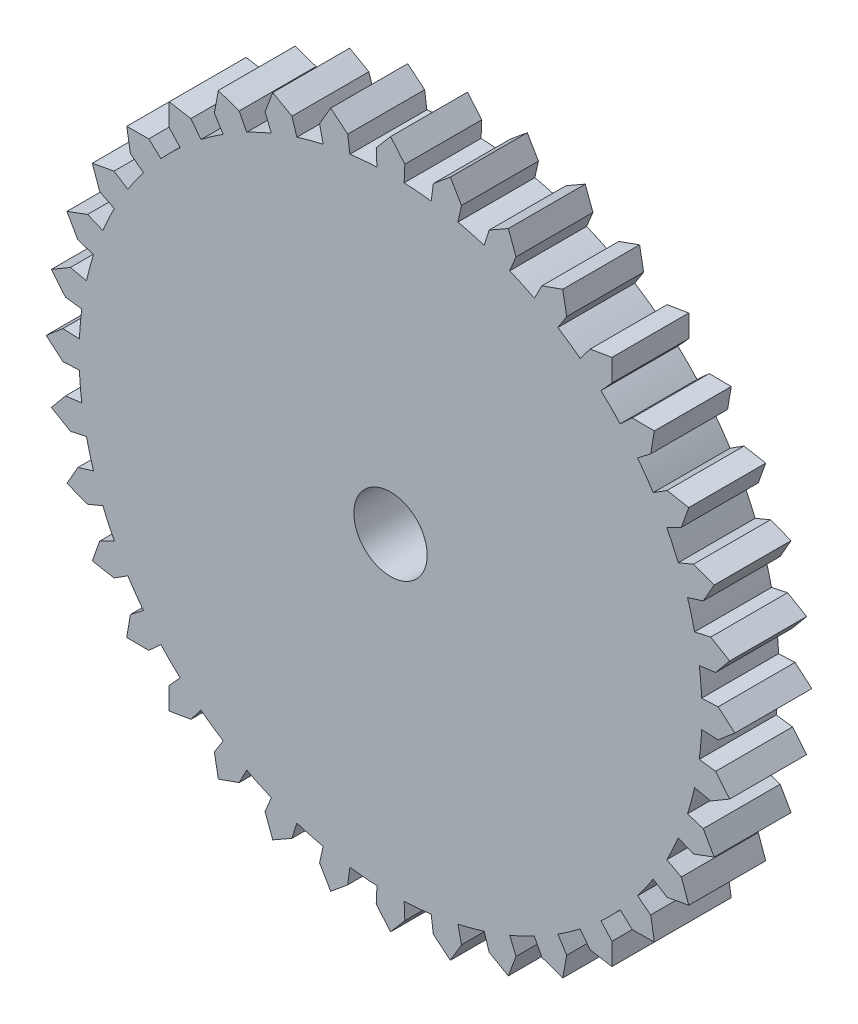
from build123d import *

# Parameters (mm, degrees)
SKETCH1_R           = 1
BOSS_EXTRUDE1_DEPTH = 2.1
SKETCH2_R           = 1
BOSS_EXTRUDE2_DEPTH = 3.5


with BuildPart() as part:
    # Sketch1 → Boss-Extrude1 (new body)
    with BuildSketch(Plane.XY):
        with BuildLine():
            Line((1.63229287, 9.257192878), (1.937134545, 8.737849264))
            Line((1.937134545, 8.737849264), (1.839736718, 8.298516061))
            ThreePointArc((1.839736718, 8.298516061), (2.020330085, 8.256407593), (2.199961883, 8.210369523))
            ThreePointArc((2.199961883, 8.210369523), (2.378546619, 8.160423762), (2.555999296, 8.106594081))
            Line((2.555999296, 8.106594081), (2.691316906, 8.535766709))
            Line((2.691316906, 8.535766709), (3.214989347, 8.833110635))
            Line((3.214989347, 8.833110635), (3.42501672, 8.268721816))
            Line((3.42501672, 8.268721816), (3.252809175, 7.852976026))
            ThreePointArc((3.252809175, 7.852976026), (3.423346864, 7.780147573), (3.592255225, 7.70361619))
            ThreePointArc((3.592255225, 7.70361619), (3.759453867, 7.623418303), (3.924863212, 7.539592082))
            Line((3.924863212, 7.539592082), (4.132650088, 7.938746957))
            Line((4.132650088, 7.938746957), (4.7, 8.140638796))
            Line((4.7, 8.140638796), (4.808831495, 7.54835344))
            Line((4.808831495, 7.54835344), (4.567046671, 7.168827289))
            ThreePointArc((4.567046671, 7.168827289), (4.722346981, 7.067491705), (4.875399709, 6.962792376))
            ThreePointArc((4.875399709, 6.962792376), (5.026132011, 6.854779136), (5.174472147, 6.743503392))
            Line((5.174472147, 6.743503392), (5.44841479, 7.100512396))
            Line((5.44841479, 7.100512396), (6.042203531, 7.200817765))
            Line((6.042203531, 7.200817765), (6.046532358, 6.598632164))
            Line((6.046532358, 6.598632164), (5.742516765, 6.266857363))
            ThreePointArc((5.742516765, 6.266857363), (5.877860974, 6.140093678), (6.01040764, 6.01040764))
            ThreePointArc((6.01040764, 6.01040764), (6.140093678, 5.877860974), (6.266857363, 5.742516765))
            Line((6.266857363, 5.742516765), (6.598632164, 6.046532358))
            Line((6.598632164, 6.046532358), (7.200817765, 6.042203531))
            Line((7.200817765, 6.042203531), (7.100512396, 5.44841479))
            Line((7.100512396, 5.44841479), (6.743503392, 5.174472147))
            ThreePointArc((6.743503392, 5.174472147), (6.854779136, 5.026132011), (6.962792376, 4.875399709))
            ThreePointArc((6.962792376, 4.875399709), (7.067491705, 4.722346981), (7.168827289, 4.567046671))
            Line((7.168827289, 4.567046671), (7.54835344, 4.808831495))
            Line((7.54835344, 4.808831495), (8.140638796, 4.7))
            Line((8.140638796, 4.7), (7.938746957, 4.132650088))
            Line((7.938746957, 4.132650088), (7.539592082, 3.924863212))
            ThreePointArc((7.539592082, 3.924863212), (7.623418303, 3.759453867), (7.70361619, 3.592255225))
            ThreePointArc((7.70361619, 3.592255225), (7.780147573, 3.423346864), (7.852976026, 3.252809175))
            Line((7.852976026, 3.252809175), (8.268721816, 3.42501672))
            Line((8.268721816, 3.42501672), (8.833110635, 3.214989347))
            Line((8.833110635, 3.214989347), (8.535766709, 2.691316906))
            Line((8.535766709, 2.691316906), (8.106594081, 2.555999296))
            ThreePointArc((8.106594081, 2.555999296), (8.160423762, 2.378546619), (8.210369523, 2.199961883))
            ThreePointArc((8.210369523, 2.199961883), (8.256407593, 2.020330085), (8.298516061, 1.839736718))
            Line((8.298516061, 1.839736718), (8.737849264, 1.937134545))
            Line((8.737849264, 1.937134545), (9.257192878, 1.63229287))
            Line((9.257192878, 1.63229287), (8.873431509, 1.16820942))
            Line((8.873431509, 1.16820942), (8.427281322, 1.109472634))
            ThreePointArc((8.427281322, 1.109472634), (8.449478875, 0.925368436), (8.467654934, 0.740823813))
            ThreePointArc((8.467654934, 0.740823813), (8.481800848, 0.555926598), (8.491909883, 0.370764793))
            Line((8.491909883, 0.370764793), (8.941481583, 0.390393517))
            Line((8.941481583, 0.390393517), (9.4, 0))
            Line((9.4, 0), (8.941481583, -0.390393517))
            Line((8.941481583, -0.390393517), (8.491909883, -0.370764793))
            ThreePointArc((8.491909883, -0.370764793), (8.481800848, -0.555926598), (8.467654934, -0.740823813))
            ThreePointArc((8.467654934, -0.740823813), (8.449478875, -0.925368436), (8.427281322, -1.109472634))
            Line((8.427281322, -1.109472634), (8.873431509, -1.16820942))
            Line((8.873431509, -1.16820942), (9.257192878, -1.63229287))
            Line((9.257192878, -1.63229287), (8.737849264, -1.937134545))
            Line((8.737849264, -1.937134545), (8.298516061, -1.839736718))
            ThreePointArc((8.298516061, -1.839736718), (8.256407593, -2.020330085), (8.210369523, -2.199961883))
            ThreePointArc((8.210369523, -2.199961883), (8.160423762, -2.378546619), (8.106594081, -2.555999296))
            Line((8.106594081, -2.555999296), (8.535766709, -2.691316906))
            Line((8.535766709, -2.691316906), (8.833110635, -3.214989347))
            Line((8.833110635, -3.214989347), (8.268721816, -3.42501672))
            Line((8.268721816, -3.42501672), (7.852976026, -3.252809175))
            ThreePointArc((7.852976026, -3.252809175), (7.780147573, -3.423346864), (7.70361619, -3.592255225))
            ThreePointArc((7.70361619, -3.592255225), (7.623418303, -3.759453867), (7.539592082, -3.924863212))
            Line((7.539592082, -3.924863212), (7.938746957, -4.132650088))
            Line((7.938746957, -4.132650088), (8.140638796, -4.7))
            Line((8.140638796, -4.7), (7.54835344, -4.808831495))
            Line((7.54835344, -4.808831495), (7.168827289, -4.567046671))
            ThreePointArc((7.168827289, -4.567046671), (7.067491705, -4.722346981), (6.962792376, -4.875399709))
            ThreePointArc((6.962792376, -4.875399709), (6.854779136, -5.026132011), (6.743503392, -5.174472147))
            Line((6.743503392, -5.174472147), (7.100512396, -5.44841479))
            Line((7.100512396, -5.44841479), (7.200817765, -6.042203531))
            Line((7.200817765, -6.042203531), (6.598632164, -6.046532358))
            Line((6.598632164, -6.046532358), (6.266857363, -5.742516765))
            ThreePointArc((6.266857363, -5.742516765), (6.140093678, -5.877860974), (6.01040764, -6.01040764))
            ThreePointArc((6.01040764, -6.01040764), (5.877860974, -6.140093678), (5.742516765, -6.266857363))
            Line((5.742516765, -6.266857363), (6.046532358, -6.598632164))
            Line((6.046532358, -6.598632164), (6.042203531, -7.200817765))
            Line((6.042203531, -7.200817765), (5.44841479, -7.100512396))
            Line((5.44841479, -7.100512396), (5.174472147, -6.743503392))
            ThreePointArc((5.174472147, -6.743503392), (5.026132011, -6.854779136), (4.875399709, -6.962792376))
            ThreePointArc((4.875399709, -6.962792376), (4.722346981, -7.067491705), (4.567046671, -7.168827289))
            Line((4.567046671, -7.168827289), (4.808831495, -7.54835344))
            Line((4.808831495, -7.54835344), (4.7, -8.140638796))
            Line((4.7, -8.140638796), (4.132650088, -7.938746957))
            Line((4.132650088, -7.938746957), (3.924863212, -7.539592082))
            ThreePointArc((3.924863212, -7.539592082), (3.759453867, -7.623418303), (3.592255225, -7.70361619))
            ThreePointArc((3.592255225, -7.70361619), (3.423346864, -7.780147573), (3.252809175, -7.852976026))
            Line((3.252809175, -7.852976026), (3.42501672, -8.268721816))
            Line((3.42501672, -8.268721816), (3.214989347, -8.833110635))
            Line((3.214989347, -8.833110635), (2.691316906, -8.535766709))
            Line((2.691316906, -8.535766709), (2.555999296, -8.106594081))
            ThreePointArc((2.555999296, -8.106594081), (2.378546619, -8.160423762), (2.199961883, -8.210369523))
            ThreePointArc((2.199961883, -8.210369523), (2.020330085, -8.256407593), (1.839736718, -8.298516061))
            Line((1.839736718, -8.298516061), (1.937134545, -8.737849264))
            Line((1.937134545, -8.737849264), (1.63229287, -9.257192878))
            Line((1.63229287, -9.257192878), (1.16820942, -8.873431509))
            Line((1.16820942, -8.873431509), (1.109472634, -8.427281322))
            ThreePointArc((1.109472634, -8.427281322), (0.925368436, -8.449478875), (0.740823813, -8.467654934))
            ThreePointArc((0.740823813, -8.467654934), (0.555926598, -8.481800848), (0.370764793, -8.491909883))
            Line((0.370764793, -8.491909883), (0.390393517, -8.941481583))
            Line((0.390393517, -8.941481583), (0, -9.4))
            Line((0, -9.4), (-0.390393517, -8.941481583))
            Line((-0.390393517, -8.941481583), (-0.370764793, -8.491909883))
            ThreePointArc((-0.370764793, -8.491909883), (-0.555926598, -8.481800848), (-0.740823813, -8.467654934))
            ThreePointArc((-0.740823813, -8.467654934), (-0.925368436, -8.449478875), (-1.109472634, -8.427281322))
            Line((-1.109472634, -8.427281322), (-1.16820942, -8.873431509))
            Line((-1.16820942, -8.873431509), (-1.63229287, -9.257192878))
            Line((-1.63229287, -9.257192878), (-1.937134545, -8.737849264))
            Line((-1.937134545, -8.737849264), (-1.839736718, -8.298516061))
            ThreePointArc((-1.839736718, -8.298516061), (-2.020330085, -8.256407593), (-2.199961883, -8.210369523))
            ThreePointArc((-2.199961883, -8.210369523), (-2.378546619, -8.160423762), (-2.555999296, -8.106594081))
            Line((-2.555999296, -8.106594081), (-2.691316906, -8.535766709))
            Line((-2.691316906, -8.535766709), (-3.214989347, -8.833110635))
            Line((-3.214989347, -8.833110635), (-3.42501672, -8.268721816))
            Line((-3.42501672, -8.268721816), (-3.252809175, -7.852976026))
            ThreePointArc((-3.252809175, -7.852976026), (-3.423346864, -7.780147573), (-3.592255225, -7.70361619))
            ThreePointArc((-3.592255225, -7.70361619), (-3.759453867, -7.623418303), (-3.924863212, -7.539592082))
            Line((-3.924863212, -7.539592082), (-4.132650088, -7.938746957))
            Line((-4.132650088, -7.938746957), (-4.7, -8.140638796))
            Line((-4.7, -8.140638796), (-4.808831495, -7.54835344))
            Line((-4.808831495, -7.54835344), (-4.567046671, -7.168827289))
            ThreePointArc((-4.567046671, -7.168827289), (-4.722346981, -7.067491705), (-4.875399709, -6.962792376))
            ThreePointArc((-4.875399709, -6.962792376), (-5.026132011, -6.854779136), (-5.174472147, -6.743503392))
            Line((-5.174472147, -6.743503392), (-5.44841479, -7.100512396))
            Line((-5.44841479, -7.100512396), (-6.042203531, -7.200817765))
            Line((-6.042203531, -7.200817765), (-6.046532358, -6.598632164))
            Line((-6.046532358, -6.598632164), (-5.742516765, -6.266857363))
            ThreePointArc((-5.742516765, -6.266857363), (-5.877860974, -6.140093678), (-6.01040764, -6.01040764))
            ThreePointArc((-6.01040764, -6.01040764), (-6.140093678, -5.877860974), (-6.266857363, -5.742516765))
            Line((-6.266857363, -5.742516765), (-6.598632164, -6.046532358))
            Line((-6.598632164, -6.046532358), (-7.200817765, -6.042203531))
            Line((-7.200817765, -6.042203531), (-7.100512396, -5.44841479))
            Line((-7.100512396, -5.44841479), (-6.743503392, -5.174472147))
            ThreePointArc((-6.743503392, -5.174472147), (-6.854779136, -5.026132011), (-6.962792376, -4.875399709))
            ThreePointArc((-6.962792376, -4.875399709), (-7.067491705, -4.722346981), (-7.168827289, -4.567046671))
            Line((-7.168827289, -4.567046671), (-7.54835344, -4.808831495))
            Line((-7.54835344, -4.808831495), (-8.140638796, -4.7))
            Line((-8.140638796, -4.7), (-7.938746957, -4.132650088))
            Line((-7.938746957, -4.132650088), (-7.539592082, -3.924863212))
            ThreePointArc((-7.539592082, -3.924863212), (-7.623418303, -3.759453867), (-7.70361619, -3.592255225))
            ThreePointArc((-7.70361619, -3.592255225), (-7.780147573, -3.423346864), (-7.852976026, -3.252809175))
            Line((-7.852976026, -3.252809175), (-8.268721816, -3.42501672))
            Line((-8.268721816, -3.42501672), (-8.833110635, -3.214989347))
            Line((-8.833110635, -3.214989347), (-8.535766709, -2.691316906))
            Line((-8.535766709, -2.691316906), (-8.106594081, -2.555999296))
            ThreePointArc((-8.106594081, -2.555999296), (-8.160423762, -2.378546619), (-8.210369523, -2.199961883))
            ThreePointArc((-8.210369523, -2.199961883), (-8.256407593, -2.020330085), (-8.298516061, -1.839736718))
            Line((-8.298516061, -1.839736718), (-8.737849264, -1.937134545))
            Line((-8.737849264, -1.937134545), (-9.257192878, -1.63229287))
            Line((-9.257192878, -1.63229287), (-8.873431509, -1.16820942))
            Line((-8.873431509, -1.16820942), (-8.427281322, -1.109472634))
            ThreePointArc((-8.427281322, -1.109472634), (-8.449478875, -0.925368436), (-8.467654934, -0.740823813))
            ThreePointArc((-8.467654934, -0.740823813), (-8.481800848, -0.555926598), (-8.491909883, -0.370764793))
            Line((-8.491909883, -0.370764793), (-8.941481583, -0.390393517))
            Line((-8.941481583, -0.390393517), (-9.4, 0))
            Line((-9.4, 0), (-8.941481583, 0.390393517))
            Line((-8.941481583, 0.390393517), (-8.491909883, 0.370764793))
            ThreePointArc((-8.491909883, 0.370764793), (-8.481800848, 0.555926598), (-8.467654934, 0.740823813))
            ThreePointArc((-8.467654934, 0.740823813), (-8.449478875, 0.925368436), (-8.427281322, 1.109472634))
            Line((-8.427281322, 1.109472634), (-8.873431509, 1.16820942))
            Line((-8.873431509, 1.16820942), (-9.257192878, 1.63229287))
            Line((-9.257192878, 1.63229287), (-8.737849264, 1.937134545))
            Line((-8.737849264, 1.937134545), (-8.298516061, 1.839736718))
            ThreePointArc((-8.298516061, 1.839736718), (-8.256407593, 2.020330085), (-8.210369523, 2.199961883))
            ThreePointArc((-8.210369523, 2.199961883), (-8.160423762, 2.378546619), (-8.106594081, 2.555999296))
            Line((-8.106594081, 2.555999296), (-8.535766709, 2.691316906))
            Line((-8.535766709, 2.691316906), (-8.833110635, 3.214989347))
            Line((-8.833110635, 3.214989347), (-8.268721816, 3.42501672))
            Line((-8.268721816, 3.42501672), (-7.852976026, 3.252809175))
            ThreePointArc((-7.852976026, 3.252809175), (-7.780147573, 3.423346864), (-7.70361619, 3.592255225))
            ThreePointArc((-7.70361619, 3.592255225), (-7.623418303, 3.759453867), (-7.539592082, 3.924863212))
            Line((-7.539592082, 3.924863212), (-7.938746957, 4.132650088))
            Line((-7.938746957, 4.132650088), (-8.140638796, 4.7))
            Line((-8.140638796, 4.7), (-7.54835344, 4.808831495))
            Line((-7.54835344, 4.808831495), (-7.168827289, 4.567046671))
            ThreePointArc((-7.168827289, 4.567046671), (-7.067491705, 4.722346981), (-6.962792376, 4.875399709))
            ThreePointArc((-6.962792376, 4.875399709), (-6.854779136, 5.026132011), (-6.743503392, 5.174472147))
            Line((-6.743503392, 5.174472147), (-7.100512396, 5.44841479))
            Line((-7.100512396, 5.44841479), (-7.200817765, 6.042203531))
            Line((-7.200817765, 6.042203531), (-6.598632164, 6.046532358))
            Line((-6.598632164, 6.046532358), (-6.266857363, 5.742516765))
            ThreePointArc((-6.266857363, 5.742516765), (-6.140093678, 5.877860974), (-6.01040764, 6.01040764))
            ThreePointArc((-6.01040764, 6.01040764), (-5.877860974, 6.140093678), (-5.742516765, 6.266857363))
            Line((-5.742516765, 6.266857363), (-6.046532358, 6.598632164))
            Line((-6.046532358, 6.598632164), (-6.042203531, 7.200817765))
            Line((-6.042203531, 7.200817765), (-5.44841479, 7.100512396))
            Line((-5.44841479, 7.100512396), (-5.174472147, 6.743503392))
            ThreePointArc((-5.174472147, 6.743503392), (-5.026132011, 6.854779136), (-4.875399709, 6.962792376))
            ThreePointArc((-4.875399709, 6.962792376), (-4.722346981, 7.067491705), (-4.567046671, 7.168827289))
            Line((-4.567046671, 7.168827289), (-4.808831495, 7.54835344))
            Line((-4.808831495, 7.54835344), (-4.7, 8.140638796))
            Line((-4.7, 8.140638796), (-4.132650088, 7.938746957))
            Line((-4.132650088, 7.938746957), (-3.924863212, 7.539592082))
            ThreePointArc((-3.924863212, 7.539592082), (-3.759453867, 7.623418303), (-3.592255225, 7.70361619))
            ThreePointArc((-3.592255225, 7.70361619), (-3.423346864, 7.780147573), (-3.252809175, 7.852976026))
            Line((-3.252809175, 7.852976026), (-3.42501672, 8.268721816))
            Line((-3.42501672, 8.268721816), (-3.214989347, 8.833110635))
            Line((-3.214989347, 8.833110635), (-2.691316906, 8.535766709))
            Line((-2.691316906, 8.535766709), (-2.555999296, 8.106594081))
            ThreePointArc((-2.555999296, 8.106594081), (-2.378546619, 8.160423762), (-2.199961883, 8.210369523))
            ThreePointArc((-2.199961883, 8.210369523), (-2.020330085, 8.256407593), (-1.839736718, 8.298516061))
            Line((-1.839736718, 8.298516061), (-1.937134545, 8.737849264))
            Line((-1.937134545, 8.737849264), (-1.63229287, 9.257192878))
            Line((-1.63229287, 9.257192878), (-1.16820942, 8.873431509))
            Line((-1.16820942, 8.873431509), (-1.109472634, 8.427281322))
            ThreePointArc((-1.109472634, 8.427281322), (-0.925368436, 8.449478875), (-0.740823813, 8.467654934))
            ThreePointArc((-0.740823813, 8.467654934), (-0.555926598, 8.481800848), (-0.370764793, 8.491909883))
            Line((-0.370764793, 8.491909883), (-0.390393517, 8.941481583))
            Line((-0.390393517, 8.941481583), (0, 9.4))
            Line((0, 9.4), (0.390393517, 8.941481583))
            Line((0.390393517, 8.941481583), (0.370764793, 8.491909883))
            ThreePointArc((0.370764793, 8.491909883), (0.555926598, 8.481800848), (0.740823813, 8.467654934))
            ThreePointArc((0.740823813, 8.467654934), (0.925368436, 8.449478875), (1.109472634, 8.427281322))
            Line((1.109472634, 8.427281322), (1.16820942, 8.873431509))
            Line((1.16820942, 8.873431509), (1.63229287, 9.257192878))
        make_face()
        Circle(SKETCH1_R, mode=Mode.SUBTRACT)
    extrude(amount=BOSS_EXTRUDE1_DEPTH)

    # Sketch2 → Boss-Extrude2 (add)
    with BuildSketch(Plane.XY):
        with BuildLine():
            Line((1.85, 3.204293994), (1.88716043, 2.459395355))
            Line((1.88716043, 2.459395355), (1.521903573, 1.983383351))
            ThreePointArc((1.521903573, 1.983383351), (1.648364538, 1.879599519), (1.767766953, 1.767766953))
            ThreePointArc((1.767766953, 1.767766953), (1.879599519, 1.648364538), (1.983383351, 1.521903573))
            Line((1.983383351, 1.521903573), (2.459395355, 1.88716043))
            Line((2.459395355, 1.88716043), (3.204293994, 1.85))
            Line((3.204293994, 1.85), (2.864026551, 1.18631864))
            Line((2.864026551, 1.18631864), (2.309698831, 0.956708581))
            ThreePointArc((2.309698831, 0.956708581), (2.367325324, 0.803598663), (2.414814566, 0.647047613))
            ThreePointArc((2.414814566, 0.647047613), (2.451963201, 0.487725805), (2.478612153, 0.326315481))
            Line((2.478612153, 0.326315481), (3.07347907, 0.404631196))
            Line((3.07347907, 0.404631196), (3.7, 0))
            Line((3.7, 0), (3.07347907, -0.404631196))
            Line((3.07347907, -0.404631196), (2.478612153, -0.326315481))
            ThreePointArc((2.478612153, -0.326315481), (2.451963201, -0.487725805), (2.414814566, -0.647047613))
            ThreePointArc((2.414814566, -0.647047613), (2.367325324, -0.803598663), (2.309698831, -0.956708581))
            Line((2.309698831, -0.956708581), (2.864026551, -1.18631864))
            Line((2.864026551, -1.18631864), (3.204293994, -1.85))
            Line((3.204293994, -1.85), (2.459395355, -1.88716043))
            Line((2.459395355, -1.88716043), (1.983383351, -1.521903573))
            ThreePointArc((1.983383351, -1.521903573), (1.879599519, -1.648364538), (1.767766953, -1.767766953))
            ThreePointArc((1.767766953, -1.767766953), (1.648364538, -1.879599519), (1.521903573, -1.983383351))
            Line((1.521903573, -1.983383351), (1.88716043, -2.459395355))
            Line((1.88716043, -2.459395355), (1.85, -3.204293994))
            Line((1.85, -3.204293994), (1.18631864, -2.864026551))
            Line((1.18631864, -2.864026551), (0.956708581, -2.309698831))
            ThreePointArc((0.956708581, -2.309698831), (0.803598663, -2.367325324), (0.647047613, -2.414814566))
            ThreePointArc((0.647047613, -2.414814566), (0.487725805, -2.451963201), (0.326315481, -2.478612153))
            Line((0.326315481, -2.478612153), (0.404631196, -3.07347907))
            Line((0.404631196, -3.07347907), (0, -3.7))
            Line((0, -3.7), (-0.404631196, -3.07347907))
            Line((-0.404631196, -3.07347907), (-0.326315481, -2.478612153))
            ThreePointArc((-0.326315481, -2.478612153), (-0.487725805, -2.451963201), (-0.647047613, -2.414814566))
            ThreePointArc((-0.647047613, -2.414814566), (-0.803598663, -2.367325324), (-0.956708581, -2.309698831))
            Line((-0.956708581, -2.309698831), (-1.18631864, -2.864026551))
            Line((-1.18631864, -2.864026551), (-1.85, -3.204293994))
            Line((-1.85, -3.204293994), (-1.88716043, -2.459395355))
            Line((-1.88716043, -2.459395355), (-1.521903573, -1.983383351))
            ThreePointArc((-1.521903573, -1.983383351), (-1.648364538, -1.879599519), (-1.767766953, -1.767766953))
            ThreePointArc((-1.767766953, -1.767766953), (-1.879599519, -1.648364538), (-1.983383351, -1.521903573))
            Line((-1.983383351, -1.521903573), (-2.459395355, -1.88716043))
            Line((-2.459395355, -1.88716043), (-3.204293994, -1.85))
            Line((-3.204293994, -1.85), (-2.864026551, -1.18631864))
            Line((-2.864026551, -1.18631864), (-2.309698831, -0.956708581))
            ThreePointArc((-2.309698831, -0.956708581), (-2.367325324, -0.803598663), (-2.414814566, -0.647047613))
            ThreePointArc((-2.414814566, -0.647047613), (-2.451963201, -0.487725805), (-2.478612153, -0.326315481))
            Line((-2.478612153, -0.326315481), (-3.07347907, -0.404631196))
            Line((-3.07347907, -0.404631196), (-3.7, 0))
            Line((-3.7, 0), (-3.07347907, 0.404631196))
            Line((-3.07347907, 0.404631196), (-2.478612153, 0.326315481))
            ThreePointArc((-2.478612153, 0.326315481), (-2.451963201, 0.487725805), (-2.414814566, 0.647047613))
            ThreePointArc((-2.414814566, 0.647047613), (-2.367325324, 0.803598663), (-2.309698831, 0.956708581))
            Line((-2.309698831, 0.956708581), (-2.864026551, 1.18631864))
            Line((-2.864026551, 1.18631864), (-3.204293994, 1.85))
            Line((-3.204293994, 1.85), (-2.459395355, 1.88716043))
            Line((-2.459395355, 1.88716043), (-1.983383351, 1.521903573))
            ThreePointArc((-1.983383351, 1.521903573), (-1.879599519, 1.648364538), (-1.767766953, 1.767766953))
            ThreePointArc((-1.767766953, 1.767766953), (-1.648364538, 1.879599519), (-1.521903573, 1.983383351))
            Line((-1.521903573, 1.983383351), (-1.88716043, 2.459395355))
            Line((-1.88716043, 2.459395355), (-1.85, 3.204293994))
            Line((-1.85, 3.204293994), (-1.18631864, 2.864026551))
            Line((-1.18631864, 2.864026551), (-0.956708581, 2.309698831))
            ThreePointArc((-0.956708581, 2.309698831), (-0.803598663, 2.367325324), (-0.647047613, 2.414814566))
            ThreePointArc((-0.647047613, 2.414814566), (-0.487725805, 2.451963201), (-0.326315481, 2.478612153))
            Line((-0.326315481, 2.478612153), (-0.404631196, 3.07347907))
            Line((-0.404631196, 3.07347907), (0, 3.7))
            Line((0, 3.7), (0.404631196, 3.07347907))
            Line((0.404631196, 3.07347907), (0.326315481, 2.478612153))
            ThreePointArc((0.326315481, 2.478612153), (0.487725805, 2.451963201), (0.647047613, 2.414814566))
            ThreePointArc((0.647047613, 2.414814566), (0.803598663, 2.367325324), (0.956708581, 2.309698831))
            Line((0.956708581, 2.309698831), (1.18631864, 2.864026551))
            Line((1.18631864, 2.864026551), (1.85, 3.204293994))
        make_face()
        Circle(SKETCH2_R, mode=Mode.SUBTRACT)
    extrude(amount=-BOSS_EXTRUDE2_DEPTH)


solid = part.part
